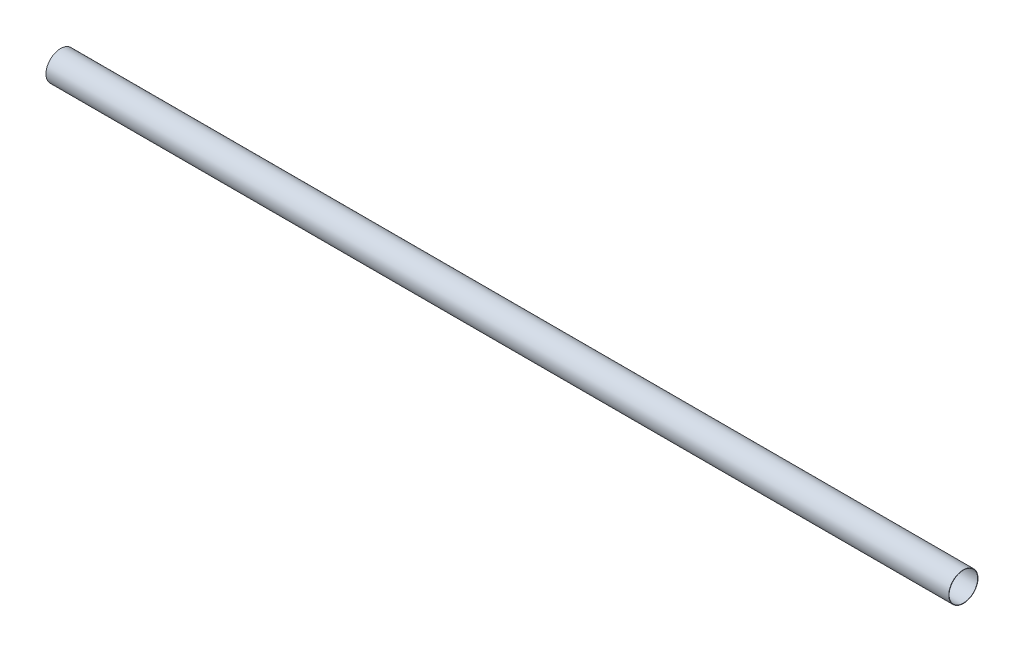
from build123d import *

# Parameters (mm, degrees)
SKETCH1_R           = 40.5
SKETCH1_R_2         = 39.5
BOSS_EXTRUDE1_DEPTH = 2500


with BuildPart() as part:
    # Sketch1 → Boss-Extrude1 (new body)
    with BuildSketch(Plane(origin=(0, 0, 0), x_dir=(0, 0, -1), z_dir=(1, 0, 0))):
        Circle(SKETCH1_R)
        Circle(SKETCH1_R_2, mode=Mode.SUBTRACT)
    extrude(amount=BOSS_EXTRUDE1_DEPTH)


solid = part.part
